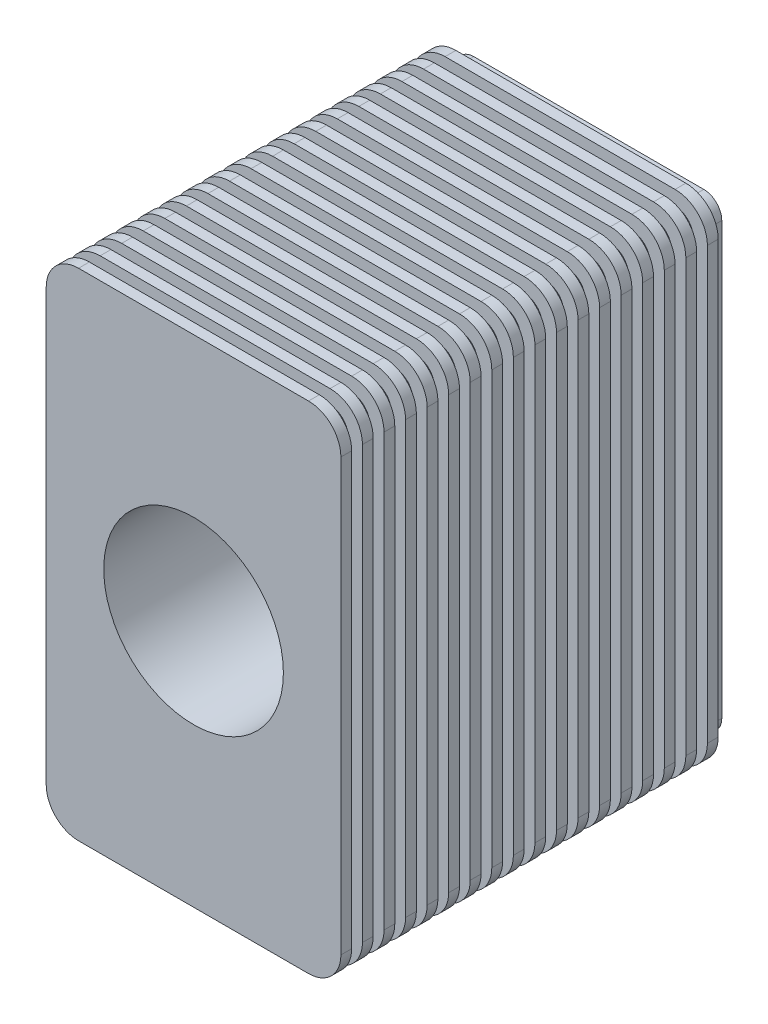
from build123d import *

# Parameters (mm, degrees)
BOSS_EXTRUDE1_DEPTH   = 550
BOSS_EXTRUDE2_DEPTH   = 30
LPATTERN1_COUNT       = 18
LPATTERN1_PITCH       = 60
MIRROR1_COPY_1_DEPTH  = 30
MIRROR1_COPY_2_DEPTH  = 30
MIRROR1_COPY_3_DEPTH  = 30
MIRROR1_COPY_4_DEPTH  = 30
MIRROR1_COPY_5_DEPTH  = 30
MIRROR1_COPY_6_DEPTH  = 30
MIRROR1_COPY_7_DEPTH  = 30
MIRROR1_COPY_8_DEPTH  = 30
MIRROR1_COPY_9_DEPTH  = 30
MIRROR1_COPY_10_DEPTH = 30
MIRROR1_COPY_11_DEPTH = 30
MIRROR1_COPY_12_DEPTH = 30
MIRROR1_COPY_13_DEPTH = 30
MIRROR1_COPY_14_DEPTH = 30
MIRROR1_COPY_15_DEPTH = 30
MIRROR1_COPY_16_DEPTH = 30
MIRROR1_COPY_17_DEPTH = 30


with BuildPart() as part:
    # Sketch1 → Boss-Extrude1 (new body, symmetric)
    with BuildSketch(Plane.XY):
        with BuildLine():
            Line((250, 0), (370, 0))
            Line((370, 0), (370, 600))
            ThreePointArc((370, 600), (355.355339059, 635.355339059), (320, 650))
            Line((320, 650), (-320, 650))
            ThreePointArc((-320, 650), (-355.355339059, 635.355339059), (-370, 600))
            Line((-370, 600), (-370, 0))
            Line((-370, 0), (-250, 0))
            ThreePointArc((-250, 0), (0, 250), (250, 0))
        make_face()
    boss_extrude1 = extrude(amount=BOSS_EXTRUDE1_DEPTH, both=True)


with BuildPart() as body_2:
    # Sketch2 → Boss-Extrude2 (new body)
    with BuildSketch(Plane.XY.offset(550)):
        with BuildLine():
            Line((320, 690), (-320, 690))
            ThreePointArc((-320, 690), (-383.639610307, 663.639610307), (-410, 600))
            Line((-410, 600), (-410, 0))
            Line((-410, 0), (-370, 0))
            Line((-370, 0), (-370, 600))
            ThreePointArc((-370, 600), (-355.355339059, 635.355339059), (-320, 650))
            Line((-320, 650), (320, 650))
            ThreePointArc((320, 650), (355.355339059, 635.355339059), (370, 600))
            Line((370, 600), (370, 0))
            Line((370, 0), (410, 0))
            Line((410, 0), (410, 600))
            ThreePointArc((410, 600), (383.639610307, 663.639610307), (320, 690))
        make_face()
    boss_extrude2 = extrude(amount=-BOSS_EXTRUDE2_DEPTH)


    add(part.part)  # Mirror1 merges part
    # Mirror1: Boss-Extrude2, Boss-Extrude1 across plane
    add(boss_extrude2.mirror(Plane(origin=(250, 0, 550), x_dir=(0, 0, 1), z_dir=(0, 1, 0))))
    add(boss_extrude1.mirror(Plane(origin=(250, 0, 550), x_dir=(0, 0, 1), z_dir=(0, 1, 0))))



with BuildPart() as lpattern1_1:
    # LPattern1: pattern copy
    add(boss_extrude2.moved(Location(Vector(0, 0, -1) * (1 * LPATTERN1_PITCH))))


with BuildPart() as lpattern1_2:
    # LPattern1: pattern copy
    add(boss_extrude2.moved(Location(Vector(0, 0, -1) * (2 * LPATTERN1_PITCH))))


with BuildPart() as lpattern1_3:
    # LPattern1: pattern copy
    add(boss_extrude2.moved(Location(Vector(0, 0, -1) * (3 * LPATTERN1_PITCH))))


with BuildPart() as lpattern1_4:
    # LPattern1: pattern copy
    add(boss_extrude2.moved(Location(Vector(0, 0, -1) * (4 * LPATTERN1_PITCH))))


with BuildPart() as lpattern1_5:
    # LPattern1: pattern copy
    add(boss_extrude2.moved(Location(Vector(0, 0, -1) * (5 * LPATTERN1_PITCH))))


with BuildPart() as lpattern1_6:
    # LPattern1: pattern copy
    add(boss_extrude2.moved(Location(Vector(0, 0, -1) * (6 * LPATTERN1_PITCH))))


with BuildPart() as lpattern1_7:
    # LPattern1: pattern copy
    add(boss_extrude2.moved(Location(Vector(0, 0, -1) * (7 * LPATTERN1_PITCH))))


with BuildPart() as lpattern1_8:
    # LPattern1: pattern copy
    add(boss_extrude2.moved(Location(Vector(0, 0, -1) * (8 * LPATTERN1_PITCH))))


with BuildPart() as lpattern1_9:
    # LPattern1: pattern copy
    add(boss_extrude2.moved(Location(Vector(0, 0, -1) * (9 * LPATTERN1_PITCH))))


with BuildPart() as lpattern1_10:
    # LPattern1: pattern copy
    add(boss_extrude2.moved(Location(Vector(0, 0, -1) * (10 * LPATTERN1_PITCH))))


with BuildPart() as lpattern1_11:
    # LPattern1: pattern copy
    add(boss_extrude2.moved(Location(Vector(0, 0, -1) * (11 * LPATTERN1_PITCH))))


with BuildPart() as lpattern1_12:
    # LPattern1: pattern copy
    add(boss_extrude2.moved(Location(Vector(0, 0, -1) * (12 * LPATTERN1_PITCH))))


with BuildPart() as lpattern1_13:
    # LPattern1: pattern copy
    add(boss_extrude2.moved(Location(Vector(0, 0, -1) * (13 * LPATTERN1_PITCH))))


with BuildPart() as lpattern1_14:
    # LPattern1: pattern copy
    add(boss_extrude2.moved(Location(Vector(0, 0, -1) * (14 * LPATTERN1_PITCH))))


with BuildPart() as lpattern1_15:
    # LPattern1: pattern copy
    add(boss_extrude2.moved(Location(Vector(0, 0, -1) * (15 * LPATTERN1_PITCH))))


with BuildPart() as lpattern1_16:
    # LPattern1: pattern copy
    add(boss_extrude2.moved(Location(Vector(0, 0, -1) * (16 * LPATTERN1_PITCH))))


with BuildPart() as lpattern1_17:
    # LPattern1: pattern copy
    add(boss_extrude2.moved(Location(Vector(0, 0, -1) * (17 * LPATTERN1_PITCH))))


with BuildPart() as body_2_1:
    add(body_2.part)

    add(lpattern1_1.part)  # Mirror1 copy 1 merges LPattern1_1
    # Mirror1 copy 1 sketch → Mirror1 copy 1 (add)
    with BuildSketch(Plane.XY.offset(490)):
        with BuildLine():
            Line((320, -690), (-320, -690))
            ThreePointArc((-320, -690), (-383.639610307, -663.639610307), (-410, -600))
            Line((-410, -600), (-410, 0))
            Line((-410, 0), (-370, 0))
            Line((-370, 0), (-370, -600))
            ThreePointArc((-370, -600), (-355.355339059, -635.355339059), (-320, -650))
            Line((-320, -650), (320, -650))
            ThreePointArc((320, -650), (355.355339059, -635.355339059), (370, -600))
            Line((370, -600), (370, 0))
            Line((370, 0), (410, 0))
            Line((410, 0), (410, -600))
            ThreePointArc((410, -600), (383.639610307, -663.639610307), (320, -690))
        make_face()
    extrude(amount=-MIRROR1_COPY_1_DEPTH)


    add(lpattern1_2.part)  # Mirror1 copy 2 merges LPattern1_2
    # Mirror1 copy 2 sketch → Mirror1 copy 2 (add)
    with BuildSketch(Plane.XY.offset(430)):
        with BuildLine():
            Line((320, -690), (-320, -690))
            ThreePointArc((-320, -690), (-383.639610307, -663.639610307), (-410, -600))
            Line((-410, -600), (-410, 0))
            Line((-410, 0), (-370, 0))
            Line((-370, 0), (-370, -600))
            ThreePointArc((-370, -600), (-355.355339059, -635.355339059), (-320, -650))
            Line((-320, -650), (320, -650))
            ThreePointArc((320, -650), (355.355339059, -635.355339059), (370, -600))
            Line((370, -600), (370, 0))
            Line((370, 0), (410, 0))
            Line((410, 0), (410, -600))
            ThreePointArc((410, -600), (383.639610307, -663.639610307), (320, -690))
        make_face()
    extrude(amount=-MIRROR1_COPY_2_DEPTH)


    add(lpattern1_3.part)  # Mirror1 copy 3 merges LPattern1_3
    # Mirror1 copy 3 sketch → Mirror1 copy 3 (add)
    with BuildSketch(Plane.XY.offset(370)):
        with BuildLine():
            Line((320, -690), (-320, -690))
            ThreePointArc((-320, -690), (-383.639610307, -663.639610307), (-410, -600))
            Line((-410, -600), (-410, 0))
            Line((-410, 0), (-370, 0))
            Line((-370, 0), (-370, -600))
            ThreePointArc((-370, -600), (-355.355339059, -635.355339059), (-320, -650))
            Line((-320, -650), (320, -650))
            ThreePointArc((320, -650), (355.355339059, -635.355339059), (370, -600))
            Line((370, -600), (370, 0))
            Line((370, 0), (410, 0))
            Line((410, 0), (410, -600))
            ThreePointArc((410, -600), (383.639610307, -663.639610307), (320, -690))
        make_face()
    extrude(amount=-MIRROR1_COPY_3_DEPTH)


    add(lpattern1_4.part)  # Mirror1 copy 4 merges LPattern1_4
    # Mirror1 copy 4 sketch → Mirror1 copy 4 (add)
    with BuildSketch(Plane.XY.offset(310)):
        with BuildLine():
            Line((320, -690), (-320, -690))
            ThreePointArc((-320, -690), (-383.639610307, -663.639610307), (-410, -600))
            Line((-410, -600), (-410, 0))
            Line((-410, 0), (-370, 0))
            Line((-370, 0), (-370, -600))
            ThreePointArc((-370, -600), (-355.355339059, -635.355339059), (-320, -650))
            Line((-320, -650), (320, -650))
            ThreePointArc((320, -650), (355.355339059, -635.355339059), (370, -600))
            Line((370, -600), (370, 0))
            Line((370, 0), (410, 0))
            Line((410, 0), (410, -600))
            ThreePointArc((410, -600), (383.639610307, -663.639610307), (320, -690))
        make_face()
    extrude(amount=-MIRROR1_COPY_4_DEPTH)


    add(lpattern1_5.part)  # Mirror1 copy 5 merges LPattern1_5
    # Mirror1 copy 5 sketch → Mirror1 copy 5 (add)
    with BuildSketch(Plane.XY.offset(250)):
        with BuildLine():
            Line((320, -690), (-320, -690))
            ThreePointArc((-320, -690), (-383.639610307, -663.639610307), (-410, -600))
            Line((-410, -600), (-410, 0))
            Line((-410, 0), (-370, 0))
            Line((-370, 0), (-370, -600))
            ThreePointArc((-370, -600), (-355.355339059, -635.355339059), (-320, -650))
            Line((-320, -650), (320, -650))
            ThreePointArc((320, -650), (355.355339059, -635.355339059), (370, -600))
            Line((370, -600), (370, 0))
            Line((370, 0), (410, 0))
            Line((410, 0), (410, -600))
            ThreePointArc((410, -600), (383.639610307, -663.639610307), (320, -690))
        make_face()
    extrude(amount=-MIRROR1_COPY_5_DEPTH)


    add(lpattern1_6.part)  # Mirror1 copy 6 merges LPattern1_6
    # Mirror1 copy 6 sketch → Mirror1 copy 6 (add)
    with BuildSketch(Plane.XY.offset(190)):
        with BuildLine():
            Line((320, -690), (-320, -690))
            ThreePointArc((-320, -690), (-383.639610307, -663.639610307), (-410, -600))
            Line((-410, -600), (-410, 0))
            Line((-410, 0), (-370, 0))
            Line((-370, 0), (-370, -600))
            ThreePointArc((-370, -600), (-355.355339059, -635.355339059), (-320, -650))
            Line((-320, -650), (320, -650))
            ThreePointArc((320, -650), (355.355339059, -635.355339059), (370, -600))
            Line((370, -600), (370, 0))
            Line((370, 0), (410, 0))
            Line((410, 0), (410, -600))
            ThreePointArc((410, -600), (383.639610307, -663.639610307), (320, -690))
        make_face()
    extrude(amount=-MIRROR1_COPY_6_DEPTH)


    add(lpattern1_7.part)  # Mirror1 copy 7 merges LPattern1_7
    # Mirror1 copy 7 sketch → Mirror1 copy 7 (add)
    with BuildSketch(Plane.XY.offset(130)):
        with BuildLine():
            Line((320, -690), (-320, -690))
            ThreePointArc((-320, -690), (-383.639610307, -663.639610307), (-410, -600))
            Line((-410, -600), (-410, 0))
            Line((-410, 0), (-370, 0))
            Line((-370, 0), (-370, -600))
            ThreePointArc((-370, -600), (-355.355339059, -635.355339059), (-320, -650))
            Line((-320, -650), (320, -650))
            ThreePointArc((320, -650), (355.355339059, -635.355339059), (370, -600))
            Line((370, -600), (370, 0))
            Line((370, 0), (410, 0))
            Line((410, 0), (410, -600))
            ThreePointArc((410, -600), (383.639610307, -663.639610307), (320, -690))
        make_face()
    extrude(amount=-MIRROR1_COPY_7_DEPTH)


    add(lpattern1_8.part)  # Mirror1 copy 8 merges LPattern1_8
    # Mirror1 copy 8 sketch → Mirror1 copy 8 (add)
    with BuildSketch(Plane.XY.offset(70)):
        with BuildLine():
            Line((320, -690), (-320, -690))
            ThreePointArc((-320, -690), (-383.639610307, -663.639610307), (-410, -600))
            Line((-410, -600), (-410, 0))
            Line((-410, 0), (-370, 0))
            Line((-370, 0), (-370, -600))
            ThreePointArc((-370, -600), (-355.355339059, -635.355339059), (-320, -650))
            Line((-320, -650), (320, -650))
            ThreePointArc((320, -650), (355.355339059, -635.355339059), (370, -600))
            Line((370, -600), (370, 0))
            Line((370, 0), (410, 0))
            Line((410, 0), (410, -600))
            ThreePointArc((410, -600), (383.639610307, -663.639610307), (320, -690))
        make_face()
    extrude(amount=-MIRROR1_COPY_8_DEPTH)


    add(lpattern1_9.part)  # Mirror1 copy 9 merges LPattern1_9
    # Mirror1 copy 9 sketch → Mirror1 copy 9 (add)
    with BuildSketch(Plane.XY.offset(10)):
        with BuildLine():
            Line((320, -690), (-320, -690))
            ThreePointArc((-320, -690), (-383.639610307, -663.639610307), (-410, -600))
            Line((-410, -600), (-410, 0))
            Line((-410, 0), (-370, 0))
            Line((-370, 0), (-370, -600))
            ThreePointArc((-370, -600), (-355.355339059, -635.355339059), (-320, -650))
            Line((-320, -650), (320, -650))
            ThreePointArc((320, -650), (355.355339059, -635.355339059), (370, -600))
            Line((370, -600), (370, 0))
            Line((370, 0), (410, 0))
            Line((410, 0), (410, -600))
            ThreePointArc((410, -600), (383.639610307, -663.639610307), (320, -690))
        make_face()
    extrude(amount=-MIRROR1_COPY_9_DEPTH)


    add(lpattern1_10.part)  # Mirror1 copy 10 merges LPattern1_10
    # Mirror1 copy 10 sketch → Mirror1 copy 10 (add)
    with BuildSketch(Plane.XY.offset(-50)):
        with BuildLine():
            Line((320, -690), (-320, -690))
            ThreePointArc((-320, -690), (-383.639610307, -663.639610307), (-410, -600))
            Line((-410, -600), (-410, 0))
            Line((-410, 0), (-370, 0))
            Line((-370, 0), (-370, -600))
            ThreePointArc((-370, -600), (-355.355339059, -635.355339059), (-320, -650))
            Line((-320, -650), (320, -650))
            ThreePointArc((320, -650), (355.355339059, -635.355339059), (370, -600))
            Line((370, -600), (370, 0))
            Line((370, 0), (410, 0))
            Line((410, 0), (410, -600))
            ThreePointArc((410, -600), (383.639610307, -663.639610307), (320, -690))
        make_face()
    extrude(amount=-MIRROR1_COPY_10_DEPTH)


    add(lpattern1_11.part)  # Mirror1 copy 11 merges LPattern1_11
    # Mirror1 copy 11 sketch → Mirror1 copy 11 (add)
    with BuildSketch(Plane.XY.offset(-110)):
        with BuildLine():
            Line((320, -690), (-320, -690))
            ThreePointArc((-320, -690), (-383.639610307, -663.639610307), (-410, -600))
            Line((-410, -600), (-410, 0))
            Line((-410, 0), (-370, 0))
            Line((-370, 0), (-370, -600))
            ThreePointArc((-370, -600), (-355.355339059, -635.355339059), (-320, -650))
            Line((-320, -650), (320, -650))
            ThreePointArc((320, -650), (355.355339059, -635.355339059), (370, -600))
            Line((370, -600), (370, 0))
            Line((370, 0), (410, 0))
            Line((410, 0), (410, -600))
            ThreePointArc((410, -600), (383.639610307, -663.639610307), (320, -690))
        make_face()
    extrude(amount=-MIRROR1_COPY_11_DEPTH)


    add(lpattern1_12.part)  # Mirror1 copy 12 merges LPattern1_12
    # Mirror1 copy 12 sketch → Mirror1 copy 12 (add)
    with BuildSketch(Plane.XY.offset(-170)):
        with BuildLine():
            Line((320, -690), (-320, -690))
            ThreePointArc((-320, -690), (-383.639610307, -663.639610307), (-410, -600))
            Line((-410, -600), (-410, 0))
            Line((-410, 0), (-370, 0))
            Line((-370, 0), (-370, -600))
            ThreePointArc((-370, -600), (-355.355339059, -635.355339059), (-320, -650))
            Line((-320, -650), (320, -650))
            ThreePointArc((320, -650), (355.355339059, -635.355339059), (370, -600))
            Line((370, -600), (370, 0))
            Line((370, 0), (410, 0))
            Line((410, 0), (410, -600))
            ThreePointArc((410, -600), (383.639610307, -663.639610307), (320, -690))
        make_face()
    extrude(amount=-MIRROR1_COPY_12_DEPTH)


    add(lpattern1_13.part)  # Mirror1 copy 13 merges LPattern1_13
    # Mirror1 copy 13 sketch → Mirror1 copy 13 (add)
    with BuildSketch(Plane.XY.offset(-230)):
        with BuildLine():
            Line((320, -690), (-320, -690))
            ThreePointArc((-320, -690), (-383.639610307, -663.639610307), (-410, -600))
            Line((-410, -600), (-410, 0))
            Line((-410, 0), (-370, 0))
            Line((-370, 0), (-370, -600))
            ThreePointArc((-370, -600), (-355.355339059, -635.355339059), (-320, -650))
            Line((-320, -650), (320, -650))
            ThreePointArc((320, -650), (355.355339059, -635.355339059), (370, -600))
            Line((370, -600), (370, 0))
            Line((370, 0), (410, 0))
            Line((410, 0), (410, -600))
            ThreePointArc((410, -600), (383.639610307, -663.639610307), (320, -690))
        make_face()
    extrude(amount=-MIRROR1_COPY_13_DEPTH)


    add(lpattern1_14.part)  # Mirror1 copy 14 merges LPattern1_14
    # Mirror1 copy 14 sketch → Mirror1 copy 14 (add)
    with BuildSketch(Plane.XY.offset(-290)):
        with BuildLine():
            Line((320, -690), (-320, -690))
            ThreePointArc((-320, -690), (-383.639610307, -663.639610307), (-410, -600))
            Line((-410, -600), (-410, 0))
            Line((-410, 0), (-370, 0))
            Line((-370, 0), (-370, -600))
            ThreePointArc((-370, -600), (-355.355339059, -635.355339059), (-320, -650))
            Line((-320, -650), (320, -650))
            ThreePointArc((320, -650), (355.355339059, -635.355339059), (370, -600))
            Line((370, -600), (370, 0))
            Line((370, 0), (410, 0))
            Line((410, 0), (410, -600))
            ThreePointArc((410, -600), (383.639610307, -663.639610307), (320, -690))
        make_face()
    extrude(amount=-MIRROR1_COPY_14_DEPTH)


    add(lpattern1_15.part)  # Mirror1 copy 15 merges LPattern1_15
    # Mirror1 copy 15 sketch → Mirror1 copy 15 (add)
    with BuildSketch(Plane.XY.offset(-350)):
        with BuildLine():
            Line((320, -690), (-320, -690))
            ThreePointArc((-320, -690), (-383.639610307, -663.639610307), (-410, -600))
            Line((-410, -600), (-410, 0))
            Line((-410, 0), (-370, 0))
            Line((-370, 0), (-370, -600))
            ThreePointArc((-370, -600), (-355.355339059, -635.355339059), (-320, -650))
            Line((-320, -650), (320, -650))
            ThreePointArc((320, -650), (355.355339059, -635.355339059), (370, -600))
            Line((370, -600), (370, 0))
            Line((370, 0), (410, 0))
            Line((410, 0), (410, -600))
            ThreePointArc((410, -600), (383.639610307, -663.639610307), (320, -690))
        make_face()
    extrude(amount=-MIRROR1_COPY_15_DEPTH)


    add(lpattern1_16.part)  # Mirror1 copy 16 merges LPattern1_16
    # Mirror1 copy 16 sketch → Mirror1 copy 16 (add)
    with BuildSketch(Plane.XY.offset(-410)):
        with BuildLine():
            Line((320, -690), (-320, -690))
            ThreePointArc((-320, -690), (-383.639610307, -663.639610307), (-410, -600))
            Line((-410, -600), (-410, 0))
            Line((-410, 0), (-370, 0))
            Line((-370, 0), (-370, -600))
            ThreePointArc((-370, -600), (-355.355339059, -635.355339059), (-320, -650))
            Line((-320, -650), (320, -650))
            ThreePointArc((320, -650), (355.355339059, -635.355339059), (370, -600))
            Line((370, -600), (370, 0))
            Line((370, 0), (410, 0))
            Line((410, 0), (410, -600))
            ThreePointArc((410, -600), (383.639610307, -663.639610307), (320, -690))
        make_face()
    extrude(amount=-MIRROR1_COPY_16_DEPTH)


    add(lpattern1_17.part)  # Mirror1 copy 17 merges LPattern1_17
    # Mirror1 copy 17 sketch → Mirror1 copy 17 (add)
    with BuildSketch(Plane.XY.offset(-470)):
        with BuildLine():
            Line((320, -690), (-320, -690))
            ThreePointArc((-320, -690), (-383.639610307, -663.639610307), (-410, -600))
            Line((-410, -600), (-410, 0))
            Line((-410, 0), (-370, 0))
            Line((-370, 0), (-370, -600))
            ThreePointArc((-370, -600), (-355.355339059, -635.355339059), (-320, -650))
            Line((-320, -650), (320, -650))
            ThreePointArc((320, -650), (355.355339059, -635.355339059), (370, -600))
            Line((370, -600), (370, 0))
            Line((370, 0), (410, 0))
            Line((410, 0), (410, -600))
            ThreePointArc((410, -600), (383.639610307, -663.639610307), (320, -690))
        make_face()
    extrude(amount=-MIRROR1_COPY_17_DEPTH)


solid = body_2_1.part
